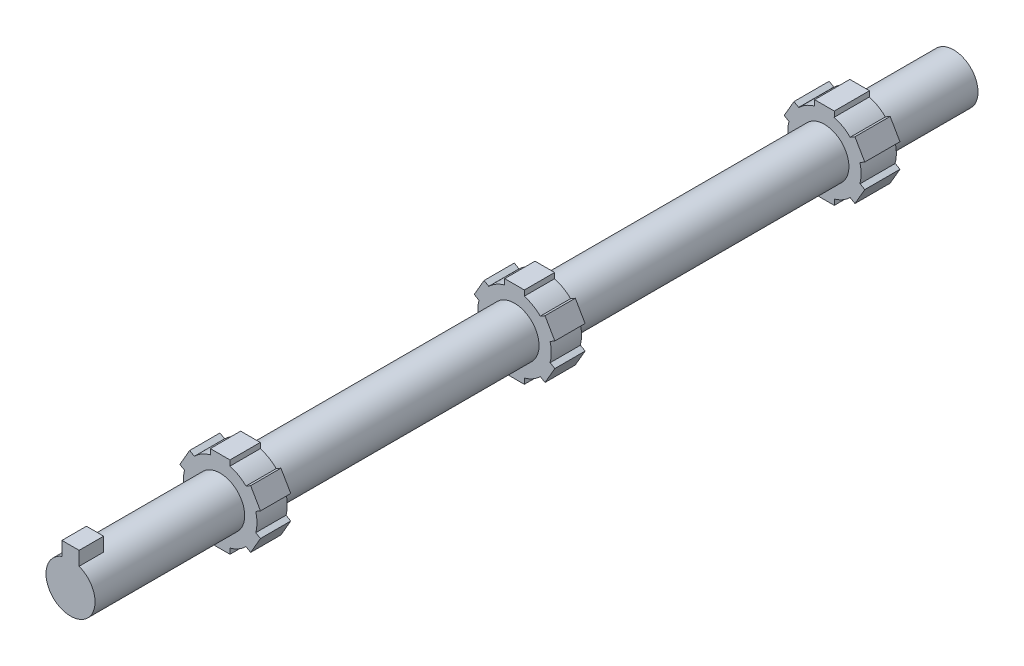
from build123d import *

# Parameters (mm, degrees)
BOSS_EXTRUDE2_START = 136.85
SKETCH4_W           = 9.2
SKETCH4_H           = 2.53
BOSS_EXTRUDE2_DEPTH = 14.2
BOSS_EXTRUDE3_START = -1.15
SKETCH4_2_W         = 9.2
SKETCH4_2_H         = 2.53
BOSS_EXTRUDE3_DEPTH = 14.2
BOSS_EXTRUDE4_START = -146.45
SKETCH4_3_W         = 9.2
SKETCH4_3_H         = 2.53
BOSS_EXTRUDE4_DEPTH = 16.5
CIRPATTERN1_COUNT   = 6
CIRPATTERN2_COUNT   = 6
CIRPATTERN3_COUNT   = 6
BOSS_EXTRUDE5_START = 207
SKETCH5_W           = 8.064124356
SKETCH5_H           = 11.5
BOSS_EXTRUDE5_DEPTH = 11.5


with BuildPart() as part:
    # Sketch3 → Revolve1 (revolve)
    with BuildSketch(Plane(origin=(0, 0, 0), x_dir=(0, 0, -1), z_dir=(1, 0, 0))):
        Polygon((-207, 11.5), (-136.85, 11.5), (-136.85, 17.25), (-122.65, 17.25), (-122.65, 11.5), (1.15, 11.5), (1.15, 17.218622442), (15.35, 17.218622442), (15.35, 11.468622442), (146.45, 11.468622442), (146.45, 17.187244885), (162.95, 17.187244885), (162.95, 11.437244885), (207, 11.437244885), (207, 0), (-207, 0), align=None)
    revolve(axis=Axis((0, 0, -207), (0, 0, 1)))

    # Sketch4 → Boss-Extrude2 (add)
    with BuildSketch(Plane.XY.offset(BOSS_EXTRUDE2_START)):
        with Locations((0, 17.895)):
            Rectangle(SKETCH4_W, SKETCH4_H)
    boss_extrude2 = extrude(amount=-BOSS_EXTRUDE2_DEPTH)

    # Sketch4_2 → Boss-Extrude3 (add)
    with BuildSketch(Plane.XY.offset(BOSS_EXTRUDE3_START)):
        with Locations((0, 17.895)):
            Rectangle(SKETCH4_2_W, SKETCH4_2_H)
    boss_extrude3 = extrude(amount=-BOSS_EXTRUDE3_DEPTH)

    # Sketch4_3 → Boss-Extrude4 (add)
    with BuildSketch(Plane.XY.offset(BOSS_EXTRUDE4_START)):
        with Locations((0, 17.895)):
            Rectangle(SKETCH4_3_W, SKETCH4_3_H)
    boss_extrude4 = extrude(amount=-BOSS_EXTRUDE4_DEPTH)

    # CirPattern1: Boss-Extrude3 ×6 about axis
    cirpattern1_axis = Axis((0, 0, 0), (0, 0, 1))
    for i in range(1, CIRPATTERN1_COUNT):
        add(boss_extrude3.rotate(cirpattern1_axis, i * 360 / CIRPATTERN1_COUNT))

    # CirPattern2: Boss-Extrude2 ×6 about axis
    cirpattern2_axis = Axis((0, 0, 0), (0, 0, 1))
    for i in range(1, CIRPATTERN2_COUNT):
        add(boss_extrude2.rotate(cirpattern2_axis, i * 360 / CIRPATTERN2_COUNT))

    # CirPattern3: Boss-Extrude4 ×6 about axis
    cirpattern3_axis = Axis((0, 0, 0), (0, 0, 1))
    for i in range(1, CIRPATTERN3_COUNT):
        add(boss_extrude4.rotate(cirpattern3_axis, i * 360 / CIRPATTERN3_COUNT))

    # Sketch5 → Boss-Extrude5 (add)
    with BuildSketch(Plane.XY.offset(BOSS_EXTRUDE5_START)):
        with Locations((0, 11.5)):
            Rectangle(SKETCH5_W, SKETCH5_H)
    extrude(amount=-BOSS_EXTRUDE5_DEPTH)


solid = part.part
